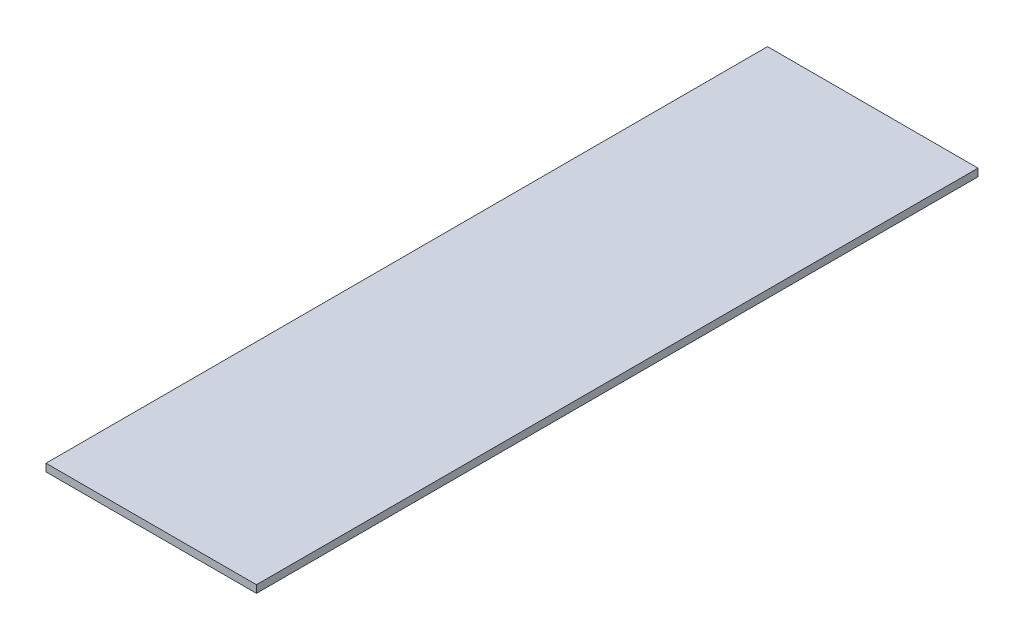
from build123d import *

# Parameters (mm, degrees)
SKETCH1_W           = 355.6
SKETCH1_H           = 1219.2
BOSS_EXTRUDE1_DEPTH = 12.7


with BuildPart() as part:
    # Sketch1 → Boss-Extrude1 (new body)
    with BuildSketch(Plane(origin=(0, 0, 0), x_dir=(1, 0, 0), z_dir=(0, 1, 0))):
        with Locations((0, 330.2)):
            Rectangle(SKETCH1_W, SKETCH1_H)
    extrude(amount=-BOSS_EXTRUDE1_DEPTH)


solid = part.part
